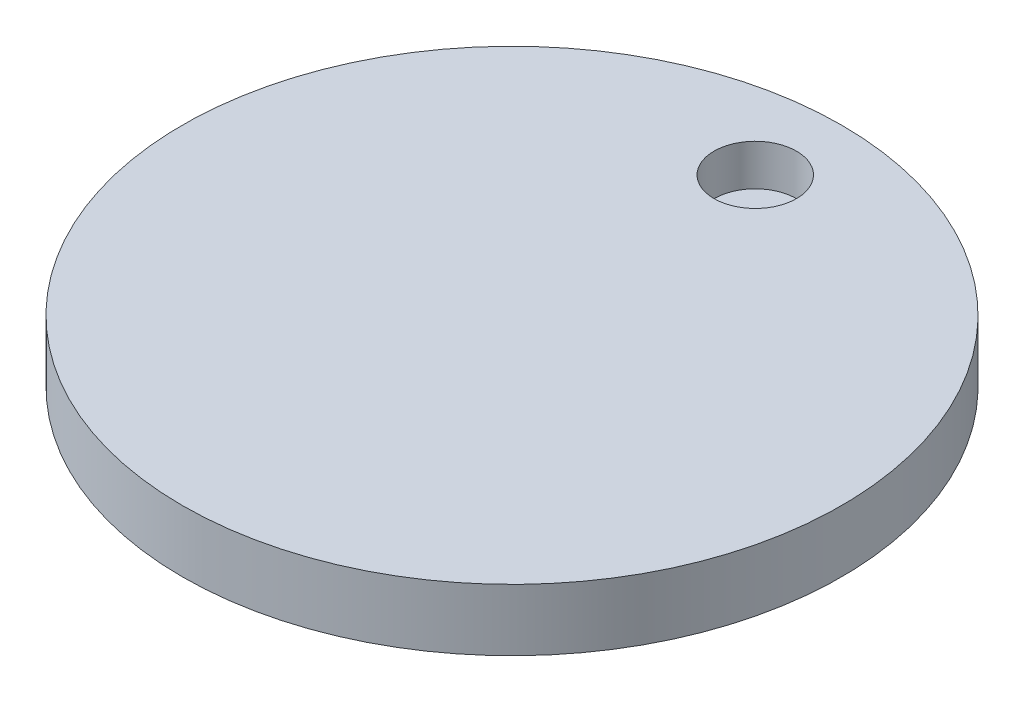
from build123d import *

# Parameters (mm, degrees)
SKETCH1_R           = 101.6
BOSS_EXTRUDE1_DEPTH = 19.05
SKETCH2_R           = 12.7
CUT_EXTRUDE1_DEPTH  = 12.7


with BuildPart() as part:
    # Sketch1 → Boss-Extrude1 (new body)
    with BuildSketch(Plane(origin=(0, 0, 0), x_dir=(1, 0, 0), z_dir=(0, 1, 0))):
        Circle(SKETCH1_R)
    extrude(amount=BOSS_EXTRUDE1_DEPTH)

    # Sketch2 → Cut-Extrude1 (cut)
    with BuildSketch(Plane(origin=(0, 19.05, 0), x_dir=(1, 0, 0), z_dir=(0, 1, 0))):
        with Locations((0, 75)):
            Circle(SKETCH2_R)
    extrude(amount=-CUT_EXTRUDE1_DEPTH, mode=Mode.SUBTRACT)


solid = part.part
